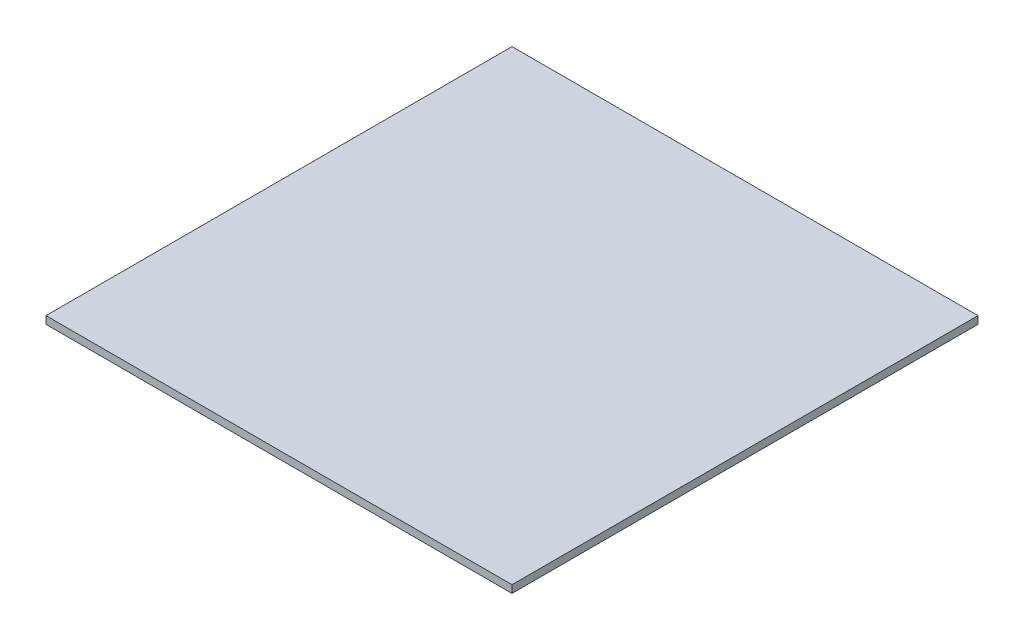
from build123d import *

# Parameters (mm, degrees)
SKETCH1_W           = 100
SKETCH1_H           = 100
BOSS_EXTRUDE1_DEPTH = 1.6256


with BuildPart() as part:
    # Sketch1 → Boss-Extrude1 (new body)
    with BuildSketch(Plane(origin=(0, 0, 0), x_dir=(1, 0, 0), z_dir=(0, 1, 0))):
        Rectangle(SKETCH1_W, SKETCH1_H)
    extrude(amount=BOSS_EXTRUDE1_DEPTH)


solid = part.part
